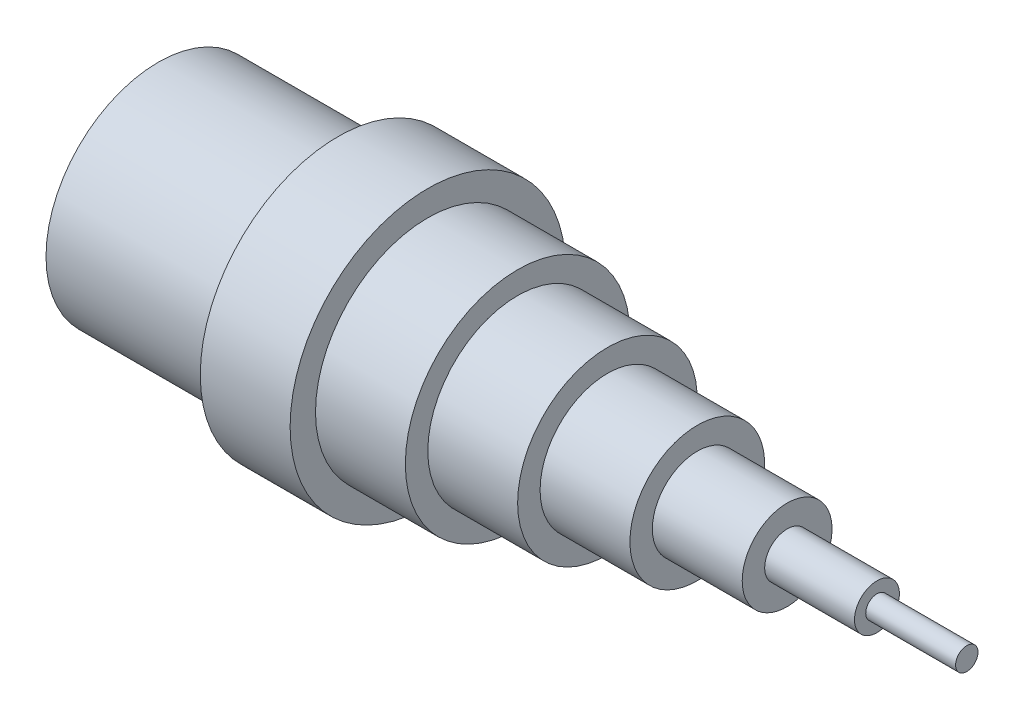
from build123d import *

# Parameters (mm, degrees)
SKETCH2_R          = 20
CUT_EXTRUDE1_DEPTH = 40


with BuildPart() as part:
    # Sketch1 → Revolve1 (revolve)
    with BuildSketch(Plane.XY, mode=Mode.PRIVATE) as revolve1_sk:
        Polygon((0, 0), (0, 25), (40, 25), (40, 30.653880235), (60, 30.653880235), (60, 25), (80, 25), (80, 20), (100, 20), (100, 15), (120, 15), (120, 10), (140, 10), (140, 5), (160, 5), (160, 2.5), (180, 2.5), (180, 0), align=None)
    revolve(revolve1_sk.sketch.rotate(Axis((0, 0, 0), (1, 0, 0)), 90), axis=Axis((0, 0, 0), (1, 0, 0)))  # turned: the seam where the file's is

    # Sketch2 → Cut-Extrude1 (cut)
    with BuildSketch(Plane.ZY):
        Circle(SKETCH2_R)
    extrude(amount=-CUT_EXTRUDE1_DEPTH, mode=Mode.SUBTRACT)


solid = part.part
